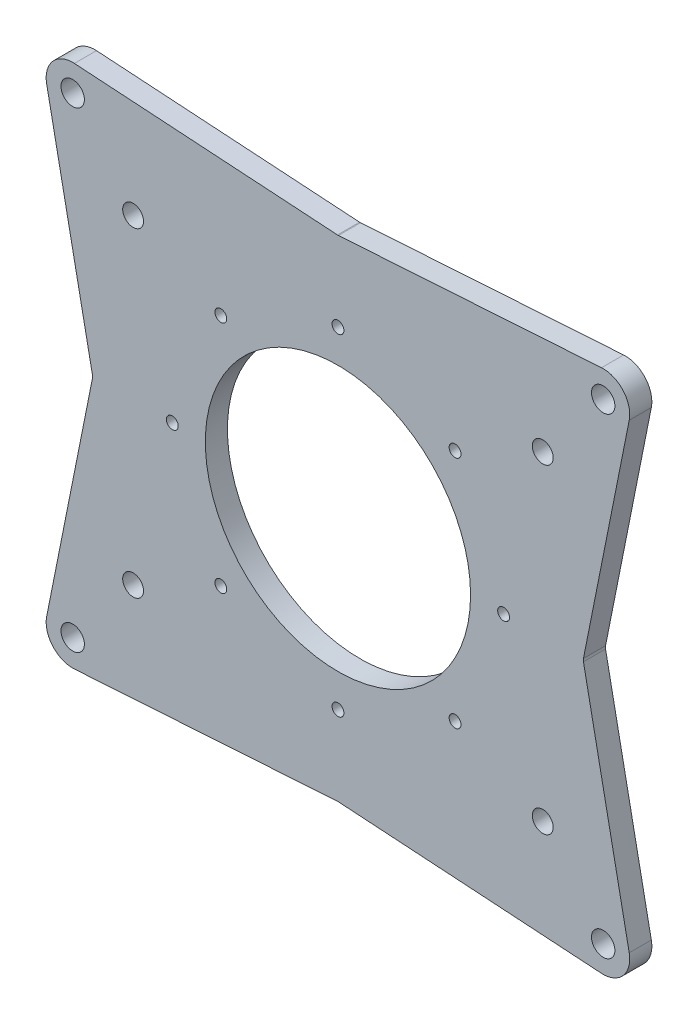
from build123d import *

# Parameters (mm, degrees)
BASE_SKETCH_R                         = 57.15
BOSS_EXTRUDE1_DEPTH                   = 9.525
CHASSIS_MOUNTING_3_8_CLEARANCE_HOLE_D = 10.0838
MOTOR_MOUNTING_M8_CLEARANCE_HOLE_D    = 9
RING_GEAR_1_4_20_TAPPED_HOLE_D        = 5.1054
CUT_EXTRUDE1_DEPTH                    = 6.35
CUT_OUT_FILLET_R                      = 3.175
OUTSIDE_CONTOUR_FILLET_R              = 3.175


with BuildPart() as part:
    # Base Sketch → Boss-Extrude1 (new body)
    with BuildSketch(Plane.XY):
        with BuildLine():
            Line((-125.508636373, 99.361390908), (-105.664, 0))
            Line((-105.664, 0), (-125.508636373, -99.361390908))
            ThreePointArc((-125.508636373, -99.361390908), (-122.899799962, -109.129165997), (-113.562553269, -113.006185704))
            Line((-113.562553269, -113.006185704), (0, -105.664))
            Line((0, -105.664), (113.562553269, -113.006185704))
            ThreePointArc((113.562553269, -113.006185704), (122.899799962, -109.129165997), (125.508636373, -99.361390908))
            Line((125.508636373, -99.361390908), (105.664, 0))
            Line((105.664, 0), (125.508636373, 99.361390908))
            ThreePointArc((125.508636373, 99.361390908), (122.899799962, 109.129165997), (113.562553269, 113.006185704))
            Line((113.562553269, 113.006185704), (0, 105.664))
            Line((0, 105.664), (-113.562553269, 113.006185704))
            ThreePointArc((-113.562553269, 113.006185704), (-122.899799962, 109.129165997), (-125.508636373, 99.361390908))
        make_face()
        Circle(BASE_SKETCH_R, mode=Mode.SUBTRACT)
    extrude(amount=BOSS_EXTRUDE1_DEPTH)

    # Chassis Mounting 3/8 Clearance Hole (through all)
    with Locations(Plane(origin=(0, 0, 0), x_dir=(-1, 0, 0), z_dir=(0, 0, -1))):
        with Locations((-114.3, 101.6), (-114.3, -101.6), (114.3, -101.6), (114.3, 101.6)):
            Hole(CHASSIS_MOUNTING_3_8_CLEARANCE_HOLE_D / 2)

    # Motor Mounting M8 Clearance Hole (through all)
    with Locations(Plane(origin=(0, 0, 0), x_dir=(-1, 0, 0), z_dir=(0, 0, -1))):
        with Locations((-88.257204359, 68.954085231), (88.257204359, 68.954085231), (88.257204359, -68.954085231), (-88.257204359, -68.954085231)):
            Hole(MOTOR_MOUNTING_M8_CLEARANCE_HOLE_D / 2)

    # Ring Gear 1/4-20 Tapped Hole (through all)
    with Locations(Plane(origin=(0, 0, 0), x_dir=(-1, 0, 0), z_dir=(0, 0, -1))):
        with Locations((-50.469742016, 50.469742016), (-71.374993648, 0), (-50.469742016, -50.469742016), (50.469742016, -50.469742016), (71.374993648, 0), (50.469742016, 50.469742016), (0, 71.374993648), (0, -71.374993648)):
            Hole(RING_GEAR_1_4_20_TAPPED_HOLE_D / 2)

    # Cut Out → Cut-Extrude1 (cut)
    with BuildSketch(Plane(origin=(0, 0, 0), x_dir=(-1, 0, 0), z_dir=(0, 0, -1))):
        with BuildLine():
            Line((95.821378977, 0), (112.094913489, 81.481010474))
            ThreePointArc((112.094913489, 81.481010474), (110.320081758, 84.981833171), (106.499405233, 84.082823648))
            Line((106.499405233, 84.082823648), (98.49124505, 74.044204201))
            ThreePointArc((98.49124505, 74.044204201), (98.515602935, 63.913236229), (90.480768801, 57.74245461))
            Line((90.480768801, 57.74245461), (79.171725028, 11.551539123))
            ThreePointArc((79.171725028, 11.551539123), (80.01, 0), (79.171725028, -11.551539123))
            Line((79.171725028, -11.551539123), (90.480768801, -57.74245461))
            ThreePointArc((90.480768801, -57.74245461), (98.515602935, -63.913236229), (98.49124505, -74.044204201))
            Line((98.49124505, -74.044204201), (106.499405233, -84.082823648))
            ThreePointArc((106.499405233, -84.082823648), (110.320081758, -84.981833171), (112.094913489, -81.481010474))
            Line((112.094913489, -81.481010474), (95.821378977, 0))
        make_face()
        with BuildLine():
            Line((46.264062358, 65.278148213), (77.76756433, 64.414002406))
            ThreePointArc((77.76756433, 64.414002406), (79.169266509, 62.021965379), (81.105665683, 60.037785855))
            Line((81.105665683, 60.037785855), (73.909080354, 30.643889132))
            ThreePointArc((73.909080354, 30.643889132), (62.532223956, 49.913135217), (46.264062358, 65.278148213))
        make_face()
        with BuildLine():
            Line((90.945970665, 80.063335239), (104.065959309, 96.50988103))
            ThreePointArc((104.065959309, 96.50988103), (103.064950406, 99.497962743), (102.9179462, 102.645825655))
            Line((102.9179462, 102.645825655), (0, 95.991848164))
            Line((0, 95.991848164), (-102.9179462, 102.645825655))
            ThreePointArc((-102.9179462, 102.645825655), (-103.064950406, 99.497962743), (-104.065959309, 96.50988103))
            Line((-104.065959309, 96.50988103), (-90.945970665, 80.063335239))
            ThreePointArc((-90.945970665, 80.063335239), (-83.440407767, 79.319574635), (-78.032220598, 74.062373308))
            Line((-78.032220598, 74.062373308), (-26.555956381, 75.474374994))
            ThreePointArc((-26.555956381, 75.474374994), (0, 80.01), (26.555956381, 75.474374994))
            Line((26.555956381, 75.474374994), (78.032220598, 74.062373308))
            ThreePointArc((78.032220598, 74.062373308), (83.440407767, 79.319574635), (90.945970665, 80.063335239))
        make_face()
        with BuildLine():
            Line((-81.105665683, 60.037785855), (-73.909080354, 30.643889132))
            ThreePointArc((-73.909080354, 30.643889132), (-62.532223956, 49.913135217), (-46.264062358, 65.278148213))
            Line((-46.264062358, 65.278148213), (-77.76756433, 64.414002406))
            ThreePointArc((-77.76756433, 64.414002406), (-79.169266509, 62.021965379), (-81.105665683, 60.037785855))
        make_face()
        with BuildLine():
            Line((-90.480768801, 57.74245461), (-79.171725028, 11.551539123))
            ThreePointArc((-79.171725028, 11.551539123), (-80.01, 0), (-79.171725028, -11.551539123))
            Line((-79.171725028, -11.551539123), (-90.480768801, -57.74245461))
            ThreePointArc((-90.480768801, -57.74245461), (-98.515602935, -63.913236229), (-98.49124505, -74.044204201))
            Line((-98.49124505, -74.044204201), (-106.499405233, -84.082823648))
            ThreePointArc((-106.499405233, -84.082823648), (-110.320081758, -84.981833171), (-112.094913489, -81.481010474))
            Line((-112.094913489, -81.481010474), (-95.821378977, 0))
            Line((-95.821378977, 0), (-112.094913489, 81.481010474))
            ThreePointArc((-112.094913489, 81.481010474), (-110.320081758, 84.981833171), (-106.499405233, 84.082823648))
            Line((-106.499405233, 84.082823648), (-98.49124505, 74.044204201))
            ThreePointArc((-98.49124505, 74.044204201), (-98.515602935, 63.913236229), (-90.480768801, 57.74245461))
        make_face()
        with BuildLine():
            Line((-46.264062358, -65.278148213), (-77.76756433, -64.414002406))
            ThreePointArc((-77.76756433, -64.414002406), (-79.169266509, -62.021965379), (-81.105665683, -60.037785855))
            Line((-81.105665683, -60.037785855), (-73.909080354, -30.643889132))
            ThreePointArc((-73.909080354, -30.643889132), (-62.532223956, -49.913135217), (-46.264062358, -65.278148213))
        make_face()
        with BuildLine():
            Line((-90.945970665, -80.063335239), (-104.065959309, -96.50988103))
            ThreePointArc((-104.065959309, -96.50988103), (-103.064950406, -99.497962743), (-102.9179462, -102.645825655))
            Line((-102.9179462, -102.645825655), (0, -95.991848164))
            Line((0, -95.991848164), (102.9179462, -102.645825655))
            ThreePointArc((102.9179462, -102.645825655), (103.064950406, -99.497962743), (104.065959309, -96.50988103))
            Line((104.065959309, -96.50988103), (90.945970665, -80.063335239))
            ThreePointArc((90.945970665, -80.063335239), (83.440407767, -79.319574635), (78.032220598, -74.062373308))
            Line((78.032220598, -74.062373308), (26.555956381, -75.474374994))
            ThreePointArc((26.555956381, -75.474374994), (0, -80.01), (-26.555956381, -75.474374994))
            Line((-26.555956381, -75.474374994), (-78.032220598, -74.062373308))
            ThreePointArc((-78.032220598, -74.062373308), (-83.440407767, -79.319574635), (-90.945970665, -80.063335239))
        make_face()
        with BuildLine():
            Line((81.105665683, -60.037785855), (73.909080354, -30.643889132))
            ThreePointArc((73.909080354, -30.643889132), (62.532223956, -49.913135217), (46.264062358, -65.278148213))
            Line((46.264062358, -65.278148213), (77.76756433, -64.414002406))
            ThreePointArc((77.76756433, -64.414002406), (79.169266509, -62.021965379), (81.105665683, -60.037785855))
        make_face()
    extrude(amount=-CUT_EXTRUDE1_DEPTH, mode=Mode.SUBTRACT)

    # Cut Out Fillet
    cut_out_fillet_edges = [part.edges().sort_by_distance(p)[0] for p in [
        (26.555956381, -75.474374994, 3.175),
        (-26.555956381, -75.474374994, 3.175),
        (-78.032220598, -74.062373308, 3.175),
        (-90.945970665, -80.063335239, 3.175),
        (-104.065959309, -96.50988103, 3.175),
        (-102.9179462, -102.645825655, 3.175),
        (0, -95.991848164, 3.175),
        (102.9179462, -102.645825655, 3.175),
        (104.065959309, -96.50988103, 3.175),
        (90.945970665, -80.063335239, 3.175),
        (78.032220598, -74.062373308, 3.175),
        (-26.555956381, 75.474374994, 3.175),
        (26.555956381, 75.474374994, 3.175),
        (78.032220598, 74.062373308, 3.175),
        (90.945970665, 80.063335239, 3.175),
        (104.065959309, 96.50988103, 3.175),
        (102.9179462, 102.645825655, 3.175),
        (0, 95.991848164, 3.175),
        (-102.9179462, 102.645825655, 3.175),
        (-104.065959309, 96.50988103, 3.175),
        (-90.945970665, 80.063335239, 3.175),
        (-78.032220598, 74.062373308, 3.175),
        (73.909080354, -30.643889132, 3.175),
        (46.264062358, -65.278148213, 3.175),
        (77.76756433, -64.414002406, 3.175),
        (81.105665683, -60.037785855, 3.175),
        (-79.171725028, -11.551539123, 3.175),
        (-79.171725028, 11.551539123, 3.175),
        (-90.480768801, 57.74245461, 3.175),
        (-98.49124505, 74.044204201, 3.175),
        (-95.821378977, 0, 3.175),
        (-98.49124505, -74.044204201, 3.175),
        (-90.480768801, -57.74245461, 3.175),
        (81.105665683, 60.037785855, 3.175),
        (77.76756433, 64.414002406, 3.175),
        (46.264062358, 65.278148213, 3.175),
        (73.909080354, 30.643889132, 3.175),
        (95.821378977, 0, 3.175),
        (98.49124505, 74.044204201, 3.175),
        (90.480768801, 57.74245461, 3.175),
        (79.171725028, 11.551539123, 3.175),
        (79.171725028, -11.551539123, 3.175),
        (90.480768801, -57.74245461, 3.175),
        (98.49124505, -74.044204201, 3.175),
        (-81.105665683, -60.037785855, 3.175),
        (-77.76756433, -64.414002406, 3.175),
        (-46.264062358, -65.278148213, 3.175),
        (-73.909080354, -30.643889132, 3.175),
        (-77.76756433, 64.414002406, 3.175),
        (-81.105665683, 60.037785855, 3.175),
        (-73.909080354, 30.643889132, 3.175),
        (-46.264062358, 65.278148213, 3.175),
    ]]
    fillet(cut_out_fillet_edges, radius=CUT_OUT_FILLET_R)

    # Outside Contour Fillet
    outside_contour_fillet_edges = [part.edges().sort_by_distance(p)[0] for p in [
        (0, 105.664, 4.7625),
        (105.664, 0, 4.7625),
        (0, -105.664, 4.7625),
        (-105.664, 0, 4.7625),
    ]]
    fillet(outside_contour_fillet_edges, radius=OUTSIDE_CONTOUR_FILLET_R)


solid = part.part
